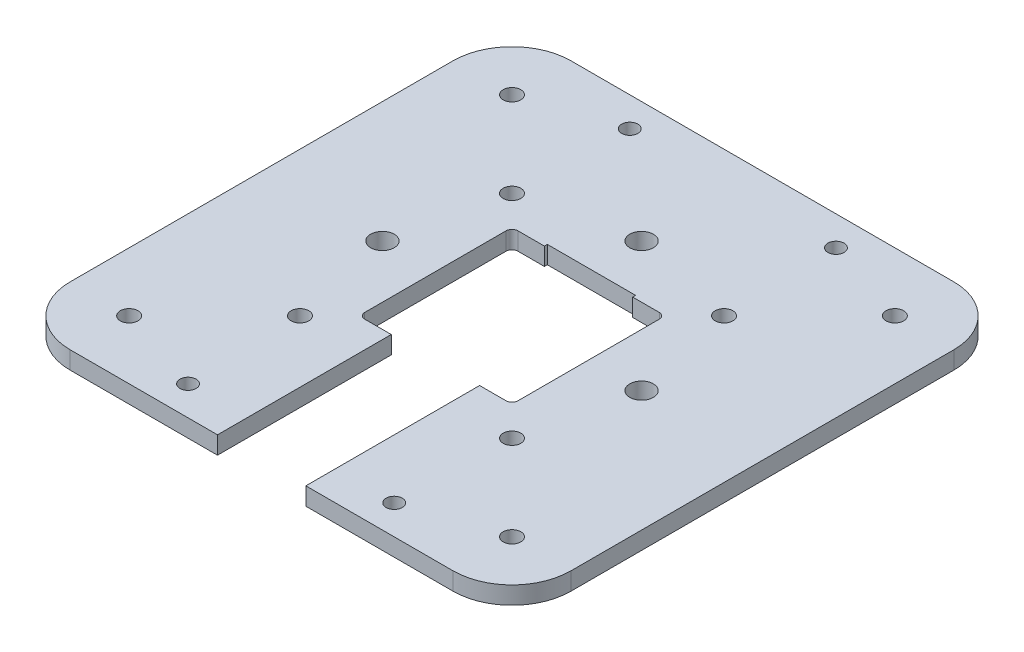
from build123d import *

# Parameters (mm, degrees)
BOSS_EXTRUDE1_DEPTH = 3
FILLET1_R           = 10
CUT_EXTRUDE1_REACH  = 5
SKETCH2_R           = 1.5
SKETCH2_R_2         = 1.375
SKETCH2_R_3         = 2
CUT_EXTRUDE2_REACH  = 5
FILLET2_R           = 1


with BuildPart() as part:
    # Sketch1 → Boss-Extrude1 (new body)
    with BuildSketch(Plane(origin=(0, 0, 0), x_dir=(1, 0, 0), z_dir=(0, 1, 0))):
        Polygon((-42.5, -42.5), (42.5, -42.5), (42.5, -25), (42.5, 25), (42.5, 42.5), (-42.5, 42.5), align=None)
    extrude(amount=BOSS_EXTRUDE1_DEPTH)

    # Fillet1
    fillet1_edges = [part.edges().sort_by_distance(p)[0] for p in [
        (42.5, 1.5, 42.5),
        (-42.5, 1.5, 42.5),
        (-42.5, 1.5, -42.5),
        (42.5, 1.5, -42.5),
    ]]
    fillet(fillet1_edges, radius=FILLET1_R)

    # Sketch2 → Cut-Extrude1 (cut, up to next)
    with BuildSketch(Plane(origin=(0, 3, 0), x_dir=(1, 0, 0), z_dir=(0, 1, 0)), mode=Mode.PRIVATE) as cut_extrude1_sk1:
        with Locations((-32.5, 32.5)):
            Circle(SKETCH2_R)
    cut_extrude1_tool1 = extrude(cut_extrude1_sk1.sketch, amount=-CUT_EXTRUDE1_REACH, mode=Mode.PRIVATE) & part.part
    add(cut_extrude1_tool1.solids().sort_by_distance((-32.5, 3, -32.5))[0], mode=Mode.SUBTRACT)
    # Sketch2 → Cut-Extrude1 (cut, up to next)
    with BuildSketch(Plane(origin=(0, 3, 0), x_dir=(1, 0, 0), z_dir=(0, 1, 0)), mode=Mode.PRIVATE) as cut_extrude1_sk2:
        with Locations((32.5, 32.5)):
            Circle(SKETCH2_R)
    cut_extrude1_tool2 = extrude(cut_extrude1_sk2.sketch, amount=-CUT_EXTRUDE1_REACH, mode=Mode.PRIVATE) & part.part
    add(cut_extrude1_tool2.solids().sort_by_distance((32.5, 3, -32.5))[0], mode=Mode.SUBTRACT)
    # Sketch2 → Cut-Extrude1 (cut, up to next)
    with BuildSketch(Plane(origin=(0, 3, 0), x_dir=(1, 0, 0), z_dir=(0, 1, 0)), mode=Mode.PRIVATE) as cut_extrude1_sk3:
        with Locations((32.5, -32.5)):
            Circle(SKETCH2_R)
    cut_extrude1_tool3 = extrude(cut_extrude1_sk3.sketch, amount=-CUT_EXTRUDE1_REACH, mode=Mode.PRIVATE) & part.part
    add(cut_extrude1_tool3.solids().sort_by_distance((32.5, 3, 32.5))[0], mode=Mode.SUBTRACT)
    # Sketch2 → Cut-Extrude1 (cut, up to next)
    with BuildSketch(Plane(origin=(0, 3, 0), x_dir=(1, 0, 0), z_dir=(0, 1, 0)), mode=Mode.PRIVATE) as cut_extrude1_sk4:
        with Locations((-32.5, -32.5)):
            Circle(SKETCH2_R)
    cut_extrude1_tool4 = extrude(cut_extrude1_sk4.sketch, amount=-CUT_EXTRUDE1_REACH, mode=Mode.PRIVATE) & part.part
    add(cut_extrude1_tool4.solids().sort_by_distance((-32.5, 3, 32.5))[0], mode=Mode.SUBTRACT)
    # Sketch2 → Cut-Extrude1 (cut, up to next)
    with BuildSketch(Plane(origin=(0, 3, 0), x_dir=(1, 0, 0), z_dir=(0, 1, 0)), mode=Mode.PRIVATE) as cut_extrude1_sk5:
        with Locations((-17.5, -37.5)):
            Circle(SKETCH2_R_2)
    cut_extrude1_tool5 = extrude(cut_extrude1_sk5.sketch, amount=-CUT_EXTRUDE1_REACH, mode=Mode.PRIVATE) & part.part
    add(cut_extrude1_tool5.solids().sort_by_distance((-17.5, 3, 37.5))[0], mode=Mode.SUBTRACT)
    # Sketch2 → Cut-Extrude1 (cut, up to next)
    with BuildSketch(Plane(origin=(0, 3, 0), x_dir=(1, 0, 0), z_dir=(0, 1, 0)), mode=Mode.PRIVATE) as cut_extrude1_sk6:
        with Locations((17.5, -37.5)):
            Circle(SKETCH2_R_2)
    cut_extrude1_tool6 = extrude(cut_extrude1_sk6.sketch, amount=-CUT_EXTRUDE1_REACH, mode=Mode.PRIVATE) & part.part
    add(cut_extrude1_tool6.solids().sort_by_distance((17.5, 3, 37.5))[0], mode=Mode.SUBTRACT)
    # Sketch2 → Cut-Extrude1 (cut, up to next)
    with BuildSketch(Plane(origin=(0, 3, 0), x_dir=(1, 0, 0), z_dir=(0, 1, 0)), mode=Mode.PRIVATE) as cut_extrude1_sk7:
        with Locations((-18, 18)):
            Circle(SKETCH2_R)
    cut_extrude1_tool7 = extrude(cut_extrude1_sk7.sketch, amount=-CUT_EXTRUDE1_REACH, mode=Mode.PRIVATE) & part.part
    add(cut_extrude1_tool7.solids().sort_by_distance((-18, 3, -18))[0], mode=Mode.SUBTRACT)
    # Sketch2 → Cut-Extrude1 (cut, up to next)
    with BuildSketch(Plane(origin=(0, 3, 0), x_dir=(1, 0, 0), z_dir=(0, 1, 0)), mode=Mode.PRIVATE) as cut_extrude1_sk8:
        with Locations((-17.5, 37.5)):
            Circle(SKETCH2_R_2)
    cut_extrude1_tool8 = extrude(cut_extrude1_sk8.sketch, amount=-CUT_EXTRUDE1_REACH, mode=Mode.PRIVATE) & part.part
    add(cut_extrude1_tool8.solids().sort_by_distance((-17.5, 3, -37.5))[0], mode=Mode.SUBTRACT)
    # Sketch2 → Cut-Extrude1 (cut, up to next)
    with BuildSketch(Plane(origin=(0, 3, 0), x_dir=(1, 0, 0), z_dir=(0, 1, 0)), mode=Mode.PRIVATE) as cut_extrude1_sk9:
        with Locations((17.5, 37.5)):
            Circle(SKETCH2_R_2)
    cut_extrude1_tool9 = extrude(cut_extrude1_sk9.sketch, amount=-CUT_EXTRUDE1_REACH, mode=Mode.PRIVATE) & part.part
    add(cut_extrude1_tool9.solids().sort_by_distance((17.5, 3, -37.5))[0], mode=Mode.SUBTRACT)
    # Sketch2 → Cut-Extrude1 (cut, up to next)
    with BuildSketch(Plane(origin=(0, 3, 0), x_dir=(1, 0, 0), z_dir=(0, 1, 0)), mode=Mode.PRIVATE) as cut_extrude1_sk10:
        with Locations((18, 18)):
            Circle(SKETCH2_R)
    cut_extrude1_tool10 = extrude(cut_extrude1_sk10.sketch, amount=-CUT_EXTRUDE1_REACH, mode=Mode.PRIVATE) & part.part
    add(cut_extrude1_tool10.solids().sort_by_distance((18, 3, -18))[0], mode=Mode.SUBTRACT)
    # Sketch2 → Cut-Extrude1 (cut, up to next)
    with BuildSketch(Plane(origin=(0, 3, 0), x_dir=(1, 0, 0), z_dir=(0, 1, 0)), mode=Mode.PRIVATE) as cut_extrude1_sk11:
        with Locations((18, -18)):
            Circle(SKETCH2_R)
    cut_extrude1_tool11 = extrude(cut_extrude1_sk11.sketch, amount=-CUT_EXTRUDE1_REACH, mode=Mode.PRIVATE) & part.part
    add(cut_extrude1_tool11.solids().sort_by_distance((18, 3, 18))[0], mode=Mode.SUBTRACT)
    # Sketch2 → Cut-Extrude1 (cut, up to next)
    with BuildSketch(Plane(origin=(0, 3, 0), x_dir=(1, 0, 0), z_dir=(0, 1, 0)), mode=Mode.PRIVATE) as cut_extrude1_sk12:
        with Locations((-18, -18)):
            Circle(SKETCH2_R)
    cut_extrude1_tool12 = extrude(cut_extrude1_sk12.sketch, amount=-CUT_EXTRUDE1_REACH, mode=Mode.PRIVATE) & part.part
    add(cut_extrude1_tool12.solids().sort_by_distance((-18, 3, 18))[0], mode=Mode.SUBTRACT)
    # Sketch2 → Cut-Extrude1 (cut, up to next)
    with BuildSketch(Plane(origin=(0, 3, 0), x_dir=(1, 0, 0), z_dir=(0, 1, 0)), mode=Mode.PRIVATE) as cut_extrude1_sk13:
        with Locations((-22, 0)):
            Circle(SKETCH2_R_3)
    cut_extrude1_tool13 = extrude(cut_extrude1_sk13.sketch, amount=-CUT_EXTRUDE1_REACH, mode=Mode.PRIVATE) & part.part
    add(cut_extrude1_tool13.solids().sort_by_distance((-22, 3, 0))[0], mode=Mode.SUBTRACT)
    # Sketch2 → Cut-Extrude1 (cut, up to next)
    with BuildSketch(Plane(origin=(0, 3, 0), x_dir=(1, 0, 0), z_dir=(0, 1, 0)), mode=Mode.PRIVATE) as cut_extrude1_sk14:
        with Locations((0, 22)):
            Circle(SKETCH2_R_3)
    cut_extrude1_tool14 = extrude(cut_extrude1_sk14.sketch, amount=-CUT_EXTRUDE1_REACH, mode=Mode.PRIVATE) & part.part
    add(cut_extrude1_tool14.solids().sort_by_distance((0, 3, -22))[0], mode=Mode.SUBTRACT)
    # Sketch2 → Cut-Extrude1 (cut, up to next)
    with BuildSketch(Plane(origin=(0, 3, 0), x_dir=(1, 0, 0), z_dir=(0, 1, 0)), mode=Mode.PRIVATE) as cut_extrude1_sk15:
        with Locations((22, 0)):
            Circle(SKETCH2_R_3)
    cut_extrude1_tool15 = extrude(cut_extrude1_sk15.sketch, amount=-CUT_EXTRUDE1_REACH, mode=Mode.PRIVATE) & part.part
    add(cut_extrude1_tool15.solids().sort_by_distance((22, 3, 0))[0], mode=Mode.SUBTRACT)
    # Sketch2 → Cut-Extrude1 (cut, up to next)
    with BuildSketch(Plane(origin=(0, 3, 0), x_dir=(1, 0, 0), z_dir=(0, 1, 0)), mode=Mode.PRIVATE) as cut_extrude1_sk16:
        with Locations((0, -22)):
            Circle(SKETCH2_R_3)
    cut_extrude1_tool16 = extrude(cut_extrude1_sk16.sketch, amount=-CUT_EXTRUDE1_REACH, mode=Mode.PRIVATE) & part.part
    add(cut_extrude1_tool16.solids().sort_by_distance((0, 3, 22))[0], mode=Mode.SUBTRACT)

    # Sketch3 → Cut-Extrude2 (cut, up to next)
    with BuildSketch(Plane.XZ, mode=Mode.PRIVATE) as cut_extrude2_sk1:
        Polygon((7.5, -13.5), (-7.5, -13.5), (-7.5, -13), (-13, -13), (-13, 13), (-7.5, 13), (-7.5, 42.5), (7.5, 42.5), (7.5, 13), (13, 13), (13, -13), (7.5, -13), align=None)
    cut_extrude2_tool1 = extrude(cut_extrude2_sk1.sketch, amount=-CUT_EXTRUDE2_REACH, mode=Mode.PRIVATE) & part.part
    add(cut_extrude2_tool1.solids().sort_by_distance((0, 0, 10.817052))[0], mode=Mode.SUBTRACT)

    # Fillet2
    fillet2_edges = [part.edges().sort_by_distance(p)[0] for p in [
        (13, 1.5, 13),
        (13, 1.5, -13),
        (-13, 1.5, -13),
        (-13, 1.5, 13),
    ]]
    fillet(fillet2_edges, radius=FILLET2_R)


solid = part.part
